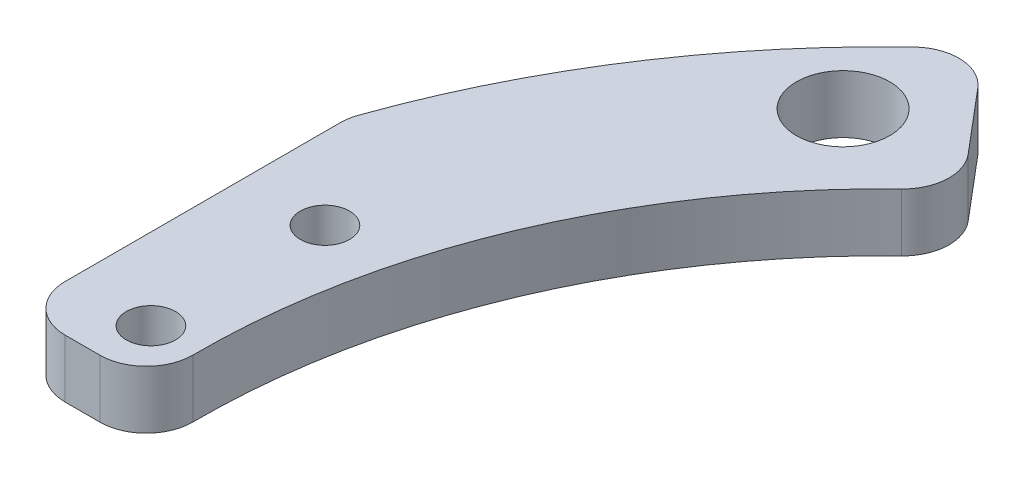
from build123d import *

# Parameters (mm, degrees)
SKETCH1_R               = 4.025
SKETCH1_R_2             = 2.125
BOSS_EXTRUDE1_DEPTH     = 5
SKETCH2_W               = 28.904595792
SKETCH2_H               = 55.332112
CUT_EXTRUDE1_DEPTH      = 1
CUT_EXTRUDE1_DEPTH_BACK = 6
SKETCH3_W               = 24.207106467
SKETCH3_H               = 21.100530829
CUT_EXTRUDE2_DEPTH      = 1
CUT_EXTRUDE2_DEPTH_BACK = 6
FILLET1_R               = 4


with BuildPart() as part:
    # Sketch1 → Boss-Extrude1 (new body)
    with BuildSketch(Plane(origin=(0, 0, 0), x_dir=(1, 0, 0), z_dir=(0, 1, 0))):
        with BuildLine():
            Line((-47.75734818, 56.526415903), (-38.07680463, 45.068358625))
            ThreePointArc((-38.07680463, 45.068358625), (-56.716415256, 16.255714087), (-56.169167779, -18.056151058))
            Line((-56.169167779, -18.056151058), (-70.449464672, -22.646697938))
            ThreePointArc((-70.449464672, -22.646697938), (-71.135842864, 20.388522754), (-47.75734818, 56.526415903))
        make_face()
        with Locations((-49.366374859, 46.034889304)):
            Circle(SKETCH1_R, mode=Mode.SUBTRACT)
        with Locations((-63, 0)):
            Circle(SKETCH1_R_2, mode=Mode.SUBTRACT)
        with Locations((-63, -15)):
            Circle(SKETCH1_R_2, mode=Mode.SUBTRACT)
        with Locations((-63, 15)):
            Circle(SKETCH1_R_2, mode=Mode.SUBTRACT)
    extrude(amount=BOSS_EXTRUDE1_DEPTH)

    # Sketch2 → Cut-Extrude1 (cut, two sides)
    with BuildSketch(Plane(origin=(0, 5, 0), x_dir=(1, 0, 0), z_dir=(0, 1, 0))) as cut_extrude1_sk:
        with Locations((-84.452297896, 0)):
            Rectangle(SKETCH2_W, SKETCH2_H)
    extrude(amount=CUT_EXTRUDE1_DEPTH, mode=Mode.SUBTRACT)
    extrude(cut_extrude1_sk.sketch, amount=-CUT_EXTRUDE1_DEPTH_BACK, mode=Mode.SUBTRACT)

    # Sketch3 → Cut-Extrude2 (cut, two sides)
    with BuildSketch(Plane(origin=(0, 5, 0), x_dir=(1, 0, 0), z_dir=(0, 1, 0))) as cut_extrude2_sk:
        with Locations((-57.896446767, -14.949043558)):
            Rectangle(SKETCH3_W, SKETCH3_H)
    extrude(amount=CUT_EXTRUDE2_DEPTH, mode=Mode.SUBTRACT)
    extrude(cut_extrude2_sk.sketch, amount=-CUT_EXTRUDE2_DEPTH_BACK, mode=Mode.SUBTRACT)

    # Fillet1
    fillet1_edges = [part.edges().sort_by_distance(p)[0] for p in [
        (-70, 2.5, -24),
        (-58.835794809, 2.5, 4.398778143),
        (-70, 2.5, 4.398778143),
        (-47.75734818, 2.5, -56.526415903),
        (-38.07680463, 2.5, -45.068358625),
    ]]
    fillet(fillet1_edges, radius=FILLET1_R)


solid = part.part
